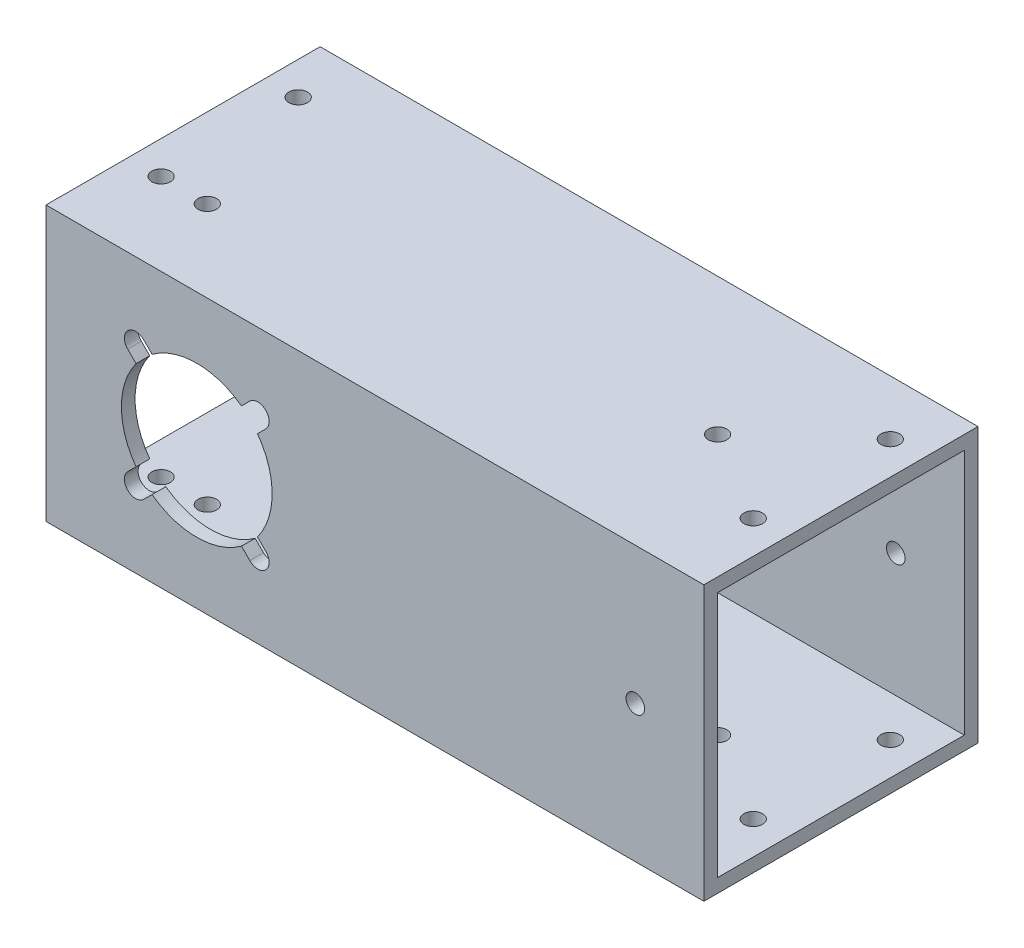
from build123d import *

# Parameters (mm, degrees)
SKETCH1_W             = 63.5
SKETCH1_H             = 63.5
BOSS_EXTRUDE1_DEPTH   = 704.85
SKETCH2_W             = 57.15
SKETCH2_H             = 57.15
CUT_EXTRUDE1_DEPTH    = 705.85
CUT_EXTRUDE2_REACH    = 65.5
SKETCH3_R             = 17.4625
SKETCH8_R             = 2.15265
CUT_EXTRUDE6_DEPTH    = 64.5
SKETCH10_R            = 2.15265
CUT_EXTRUDE7_DEPTH    = 64.5
CUT_EXTRUDE9_REACH    = 65.5
SKETCH13_R            = 16
SKETCH14_R            = 2.625
SKETCH14_R_2          = 16
CUT_EXTRUDE10_DEPTH   = 3.175
CUT_EXTRUDE11_START   = -3.175
CUT_EXTRUDE11_DEPTH   = 3.175
CUT_EXTRUDE13_REACH   = 65.5
SKETCH17_W            = 19.05
SKETCH17_H            = 25.4
SKETCH18_W            = 63.5
SKETCH18_H            = 63.5
CUT_EXTRUDE14_DEPTH   = 552.45
F_8_CLEARANCE_HOLE1_D = 4.3053
SKETCH21_R            = 2.15265
CUT_EXTRUDE15_DEPTH   = 6.35
SKETCH22_R            = 2.15265
CUT_EXTRUDE16_DEPTH   = 6.35


with BuildPart() as part:
    # Sketch1 → Boss-Extrude1 (new body)
    with BuildSketch(Plane(origin=(0, 0, 0), x_dir=(0, 0, -1), z_dir=(1, 0, 0))):
        Rectangle(SKETCH1_W, SKETCH1_H)
    extrude(amount=BOSS_EXTRUDE1_DEPTH)

    # Sketch2 → Cut-Extrude1 (cut, through all)
    with BuildSketch(Plane(origin=(704.85, 0, 0), x_dir=(0, 0, -1), z_dir=(1, 0, 0))):
        Rectangle(SKETCH2_W, SKETCH2_H)
    extrude(amount=-CUT_EXTRUDE1_DEPTH, mode=Mode.SUBTRACT)

    # Sketch3 → Cut-Extrude2 (cut, up to next)
    with BuildSketch(Plane.XY.offset(31.75), mode=Mode.PRIVATE) as cut_extrude2_sk1:
        with Locations((352.425, 0)):
            Circle(SKETCH3_R)
    cut_extrude2_tool1 = extrude(cut_extrude2_sk1.sketch, amount=-CUT_EXTRUDE2_REACH, mode=Mode.PRIVATE) & part.part
    add(cut_extrude2_tool1.solids().sort_by_distance((352.425, 0, 31.75))[0], mode=Mode.SUBTRACT)
    # Sketch3 → Cut-Extrude2 (cut, up to next)
    with BuildSketch(Plane.XY.offset(31.75), mode=Mode.PRIVATE) as cut_extrude2_sk2:
        with Locations((34.925, 0)):
            Circle(SKETCH3_R)
    cut_extrude2_tool2 = extrude(cut_extrude2_sk2.sketch, amount=-CUT_EXTRUDE2_REACH, mode=Mode.PRIVATE) & part.part
    add(cut_extrude2_tool2.solids().sort_by_distance((34.925, 0, 31.75))[0], mode=Mode.SUBTRACT)
    # Sketch3 → Cut-Extrude2 (cut, up to next)
    with BuildSketch(Plane.XY.offset(31.75), mode=Mode.PRIVATE) as cut_extrude2_sk3:
        with Locations((669.925, 0)):
            Circle(SKETCH3_R)
    cut_extrude2_tool3 = extrude(cut_extrude2_sk3.sketch, amount=-CUT_EXTRUDE2_REACH, mode=Mode.PRIVATE) & part.part
    add(cut_extrude2_tool3.solids().sort_by_distance((669.925, 0, 31.75))[0], mode=Mode.SUBTRACT)

    # Sketch8 → Cut-Extrude6 (cut, through all)
    with BuildSketch(Plane(origin=(0, 31.75, 0), x_dir=(1, 0, 0), z_dir=(0, 1, 0))):
        with Locations((466.725, 0)):
            Circle(SKETCH8_R)
        with Locations((123.825, 0)):
            Circle(SKETCH8_R)
        with Locations((581.025, 0)):
            Circle(SKETCH8_R)
        with Locations((238.125, 0)):
            Circle(SKETCH8_R)
    extrude(amount=-CUT_EXTRUDE6_DEPTH, mode=Mode.SUBTRACT)

    # Sketch10 → Cut-Extrude7 (cut, through all)
    with BuildSketch(Plane.XY.offset(31.75)):
        with Locations((225.425, 0)):
            Circle(SKETCH10_R)
        with Locations((568.325, 0)):
            Circle(SKETCH10_R)
        with Locations((136.525, 0)):
            Circle(SKETCH10_R)
        with Locations((479.425, 0)):
            Circle(SKETCH10_R)
    extrude(amount=-CUT_EXTRUDE7_DEPTH, mode=Mode.SUBTRACT)

    # Sketch13 → Cut-Extrude9 (cut, up to next)
    with BuildSketch(Plane(origin=(0, 0, -31.75), x_dir=(-1, 0, 0), z_dir=(0, 0, -1)), mode=Mode.PRIVATE) as cut_extrude9_sk1:
        with Locations((-352.425, 0)):
            Circle(SKETCH13_R)
    cut_extrude9_tool1 = extrude(cut_extrude9_sk1.sketch, amount=-CUT_EXTRUDE9_REACH, mode=Mode.PRIVATE) & part.part
    add(cut_extrude9_tool1.solids().sort_by_distance((352.425, 0, -31.75))[0], mode=Mode.SUBTRACT)
    # Sketch13 → Cut-Extrude9 (cut, up to next)
    with BuildSketch(Plane(origin=(0, 0, -31.75), x_dir=(-1, 0, 0), z_dir=(0, 0, -1)), mode=Mode.PRIVATE) as cut_extrude9_sk2:
        with Locations((-34.925, 0)):
            Circle(SKETCH13_R)
    cut_extrude9_tool2 = extrude(cut_extrude9_sk2.sketch, amount=-CUT_EXTRUDE9_REACH, mode=Mode.PRIVATE) & part.part
    add(cut_extrude9_tool2.solids().sort_by_distance((34.925, 0, -31.75))[0], mode=Mode.SUBTRACT)
    # Sketch13 → Cut-Extrude9 (cut, up to next)
    with BuildSketch(Plane(origin=(0, 0, -31.75), x_dir=(-1, 0, 0), z_dir=(0, 0, -1)), mode=Mode.PRIVATE) as cut_extrude9_sk3:
        with Locations((-669.925, 0)):
            Circle(SKETCH13_R)
    cut_extrude9_tool3 = extrude(cut_extrude9_sk3.sketch, amount=-CUT_EXTRUDE9_REACH, mode=Mode.PRIVATE) & part.part
    add(cut_extrude9_tool3.solids().sort_by_distance((669.925, 0, -31.75))[0], mode=Mode.SUBTRACT)

    # Sketch14 → Cut-Extrude10 (cut)
    with BuildSketch(Plane(origin=(0, 0, -31.75), x_dir=(-1, 0, 0), z_dir=(0, 0, -1))):
        with Locations((-655.782864376, 14.142135624)):
            Circle(SKETCH14_R)
        with Locations((-338.282864376, 14.142135624)):
            Circle(SKETCH14_R)
        with Locations((-20.782864376, 14.142135624)):
            Circle(SKETCH14_R)
        with Locations((-352.425, 0)):
            Circle(SKETCH14_R_2)
        with Locations((-34.925, 0)):
            Circle(SKETCH14_R_2)
        with Locations((-669.925, 0)):
            Circle(SKETCH14_R_2)
        with Locations((-338.282864376, -14.142135624)):
            Circle(SKETCH14_R)
        with Locations((-366.567135624, -14.142135624)):
            Circle(SKETCH14_R)
        with Locations((-366.567135624, 14.142135624)):
            Circle(SKETCH14_R)
        with Locations((-20.782864376, -14.142135624)):
            Circle(SKETCH14_R)
        with Locations((-49.067135624, -14.142135624)):
            Circle(SKETCH14_R)
        with Locations((-49.067135624, 14.142135624)):
            Circle(SKETCH14_R)
        with Locations((-655.782864376, -14.142135624)):
            Circle(SKETCH14_R)
        with Locations((-684.067135624, -14.142135624)):
            Circle(SKETCH14_R)
        with Locations((-684.067135624, 14.142135624)):
            Circle(SKETCH14_R)
    extrude(amount=-CUT_EXTRUDE10_DEPTH, mode=Mode.SUBTRACT)

    # Sketch15 → Cut-Extrude11 (cut)
    with BuildSketch(Plane.XY.offset(31.75).offset(CUT_EXTRUDE11_START)):
        with BuildLine():
            Line((364.710980323, -15.998290924), (362.776389114, -14.063699715))
            ThreePointArc((362.776389114, -14.063699715), (352.425, -17.4625), (342.073610886, -14.063699715))
            Line((342.073610886, -14.063699715), (340.139019677, -15.998290924))
            ThreePointArc((340.139019677, -15.998290924), (336.426709076, -15.998290924), (336.426709076, -12.285980323))
            Line((336.426709076, -12.285980323), (338.361300285, -10.351389114))
            ThreePointArc((338.361300285, -10.351389114), (334.9625, 0), (338.361300285, 10.351389114))
            Line((338.361300285, 10.351389114), (336.426709076, 12.285980323))
            ThreePointArc((336.426709076, 12.285980323), (336.426709076, 15.998290924), (340.139019677, 15.998290924))
            Line((340.139019677, 15.998290924), (342.073610886, 14.063699715))
            ThreePointArc((342.073610886, 14.063699715), (352.425, 17.4625), (362.776389114, 14.063699715))
            Line((362.776389114, 14.063699715), (364.710980323, 15.998290924))
            ThreePointArc((364.710980323, 15.998290924), (368.423290924, 15.998290924), (368.423290924, 12.285980323))
            Line((368.423290924, 12.285980323), (366.488699715, 10.351389114))
            ThreePointArc((366.488699715, 10.351389114), (369.8875, 0), (366.488699715, -10.351389114))
            Line((366.488699715, -10.351389114), (368.423290924, -12.285980323))
            ThreePointArc((368.423290924, -12.285980323), (368.423290924, -15.998290924), (364.710980323, -15.998290924))
        make_face()
        with BuildLine():
            Line((50.923290924, 12.285980323), (48.988699715, 10.351389114))
            ThreePointArc((48.988699715, 10.351389114), (52.3875, 0), (48.988699715, -10.351389114))
            Line((48.988699715, -10.351389114), (50.923290924, -12.285980323))
            ThreePointArc((50.923290924, -12.285980323), (50.923290924, -15.998290924), (47.210980323, -15.998290924))
            Line((47.210980323, -15.998290924), (45.276389114, -14.063699715))
            ThreePointArc((45.276389114, -14.063699715), (34.925, -17.4625), (24.573610886, -14.063699715))
            Line((24.573610886, -14.063699715), (22.639019677, -15.998290924))
            ThreePointArc((22.639019677, -15.998290924), (18.926709076, -15.998290924), (18.926709076, -12.285980323))
            Line((18.926709076, -12.285980323), (20.861300285, -10.351389114))
            ThreePointArc((20.861300285, -10.351389114), (17.4625, 0), (20.861300285, 10.351389114))
            Line((20.861300285, 10.351389114), (18.926709076, 12.285980323))
            ThreePointArc((18.926709076, 12.285980323), (18.926709076, 15.998290924), (22.639019677, 15.998290924))
            Line((22.639019677, 15.998290924), (24.573610886, 14.063699715))
            ThreePointArc((24.573610886, 14.063699715), (34.925, 17.4625), (45.276389114, 14.063699715))
            Line((45.276389114, 14.063699715), (47.210980323, 15.998290924))
            ThreePointArc((47.210980323, 15.998290924), (50.923290924, 15.998290924), (50.923290924, 12.285980323))
        make_face()
        with BuildLine():
            Line((685.923290924, 12.285980323), (683.988699715, 10.351389114))
            ThreePointArc((683.988699715, 10.351389114), (687.3875, 0), (683.988699715, -10.351389114))
            Line((683.988699715, -10.351389114), (685.923290924, -12.285980323))
            ThreePointArc((685.923290924, -12.285980323), (685.923290924, -15.998290924), (682.210980323, -15.998290924))
            Line((682.210980323, -15.998290924), (680.276389114, -14.063699715))
            ThreePointArc((680.276389114, -14.063699715), (669.925, -17.4625), (659.573610886, -14.063699715))
            Line((659.573610886, -14.063699715), (657.639019677, -15.998290924))
            ThreePointArc((657.639019677, -15.998290924), (653.926709076, -15.998290924), (653.926709076, -12.285980323))
            Line((653.926709076, -12.285980323), (655.861300285, -10.351389114))
            ThreePointArc((655.861300285, -10.351389114), (652.4625, 0), (655.861300285, 10.351389114))
            Line((655.861300285, 10.351389114), (653.926709076, 12.285980323))
            ThreePointArc((653.926709076, 12.285980323), (653.926709076, 15.998290924), (657.639019677, 15.998290924))
            Line((657.639019677, 15.998290924), (659.573610886, 14.063699715))
            ThreePointArc((659.573610886, 14.063699715), (669.925, 17.4625), (680.276389114, 14.063699715))
            Line((680.276389114, 14.063699715), (682.210980323, 15.998290924))
            ThreePointArc((682.210980323, 15.998290924), (685.923290924, 15.998290924), (685.923290924, 12.285980323))
        make_face()
    extrude(amount=CUT_EXTRUDE11_DEPTH, mode=Mode.SUBTRACT)

    # Sketch17 → Cut-Extrude13 (cut, up to next)
    with BuildSketch(Plane.XZ.offset(31.75), mode=Mode.PRIVATE) as cut_extrude13_sk1:
        with Locations((352.425, -12.7)):
            Rectangle(SKETCH17_W, SKETCH17_H)
    cut_extrude13_tool1 = extrude(cut_extrude13_sk1.sketch, amount=-CUT_EXTRUDE13_REACH, mode=Mode.PRIVATE) & part.part
    add(cut_extrude13_tool1.solids().sort_by_distance((352.425, -31.75, -12.7))[0], mode=Mode.SUBTRACT)

    # Sketch18 → Cut-Extrude14 (cut)
    with BuildSketch(Plane(origin=(704.85, 0, 0), x_dir=(0, 0, -1), z_dir=(1, 0, 0))):
        Rectangle(SKETCH18_W, SKETCH18_H)
    extrude(amount=-CUT_EXTRUDE14_DEPTH, mode=Mode.SUBTRACT)

    # #8 Clearance Hole1 (through all)
    with Locations(Plane(origin=(0, 31.75, 0), x_dir=(1, 0, 0), z_dir=(0, 1, 0))):
        with Locations((7.62, 19.05), (7.62, -12.7), (144.78, -12.7), (144.78, 19.05)):
            Hole(F_8_CLEARANCE_HOLE1_D / 2)

    # Sketch21 → Cut-Extrude15 (cut)
    with BuildSketch(Plane(origin=(0, 31.75, 0), x_dir=(1, 0, 0), z_dir=(0, 1, 0))):
        with Locations((18.4785, -12.85875)):
            Circle(SKETCH21_R)
    extrude(amount=-CUT_EXTRUDE15_DEPTH, mode=Mode.SUBTRACT)

    # Sketch22 → Cut-Extrude16 (cut)
    with BuildSketch(Plane(origin=(0, -28.575, 0), x_dir=(1, 0, 0), z_dir=(0, 1, 0))):
        with Locations((18.4785, -12.85875)):
            Circle(SKETCH22_R)
    extrude(amount=-CUT_EXTRUDE16_DEPTH, mode=Mode.SUBTRACT)


solid = part.part
